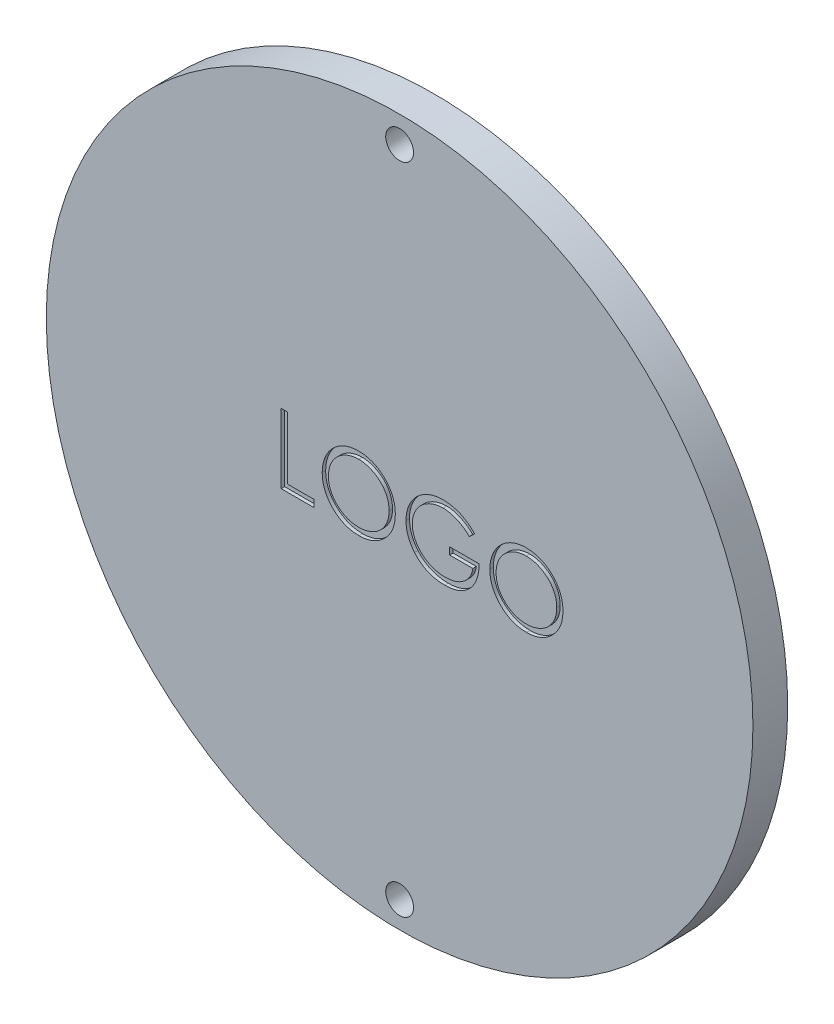
from build123d import *

# Parameters (mm, degrees)
ESQUISSE1_R             = 50.8
BOSS_EXTRU_1_DEPTH      = 5
ESQUISSE2_R             = 2
ENL_V_MAT_EXTRU_1_DEPTH = 6
ENL_V_MAT_EXTRU_2_DEPTH = 0.5


with BuildPart() as part:
    # Esquisse1 → Boss.-Extru.1 (new body)
    with BuildSketch(Plane.XY):
        Circle(ESQUISSE1_R)
    extrude(amount=BOSS_EXTRU_1_DEPTH)

    # Esquisse2 → Enlèv. mat.-Extru.1 (cut, through all)
    with BuildSketch(Plane.XY.offset(5)):
        with Locations((0, 47)):
            Circle(ESQUISSE2_R)
        with Locations((0, -47)):
            Circle(ESQUISSE2_R)
    extrude(amount=-ENL_V_MAT_EXTRU_1_DEPTH, mode=Mode.SUBTRACT)

    # Esquisse4 → Enlèv. mat.-Extru.2 (cut)
    with BuildSketch(Plane.XY.offset(5)):
        Polygon((-17.027461498, 5.640911659), (-16.1300256, 5.640911659), (-16.1300256, -3.333447315), (-12.283871754, -3.333447315), (-12.283871754, -4.359088341), (-17.027461498, -4.359088341), align=None)
        with BuildLine():
            add(Edge.make_bspline(
                [(-5.937717908, 5.897321916), (-5.752551891, 5.892631975), (-5.388870557, 5.883420544), (-4.854370849, 5.812908819), (-4.344099148, 5.690921991), (-3.853898752, 5.528456326), (-3.389633104, 5.311729511), (-2.947807697, 5.049771944), (-2.529473772, 4.739839205), (-2.140269825, 4.384327128), (-1.78410711, 3.99751726), (-1.470318863, 3.584723231), (-1.207340881, 3.148440939), (-0.991381489, 2.689981423), (-0.82195689, 2.210381514), (-0.705045337, 1.707084364), (-0.630364908, 1.183350963), (-0.621634115, 0.82613135), (-0.617205087, 0.64491807)],
                knots=[0, 0, 0, 0, 0.000555408, 0.001090868, 0.001613685, 0.002127432, 0.002637404, 0.003147577, 0.003666016, 0.004196393, 0.004726641, 0.005241469, 0.005749233, 0.006251945, 0.006759421, 0.00727203, 0.007799817, 0.008343217, 0.008343217, 0.008343217, 0.008343217], degree=3))
            add(Edge.make_bspline(
                [(-0.617205087, 0.64491807), (-0.621633466, 0.465039652), (-0.630362313, 0.11047845), (-0.705130249, -0.40993139), (-0.822390249, -0.910190523), (-0.989808152, -1.389463817), (-1.204738091, -1.848256856), (-1.469467151, -2.285362439), (-1.781299182, -2.700923862), (-2.136175899, -3.09038862), (-2.523036019, -3.447524251), (-2.937979639, -3.758721038), (-3.371674838, -4.026504252), (-3.829702576, -4.240171892), (-4.305988396, -4.410948807), (-4.804795033, -4.527384893), (-5.323785187, -4.602490731), (-5.677702341, -4.611115062), (-5.857589703, -4.615498597)],
                knots=[0, 0, 0, 0, 0.000539398, 0.001063216, 0.001573876, 0.002078799, 0.002583325, 0.003091089, 0.003609118, 0.004139494, 0.004669742, 0.005186169, 0.005693261, 0.006195974, 0.006699672, 0.007208383, 0.007730217, 0.008269615, 0.008269615, 0.008269615, 0.008269615], degree=3))
            add(Edge.make_bspline(
                [(-5.857589703, -4.615498597), (-6.038802043, -4.611071777), (-6.396019802, -4.602345338), (-6.920411332, -4.527541324), (-7.424062029, -4.41056617), (-7.905531604, -4.243396352), (-8.365088545, -4.027347122), (-8.803631639, -3.763906039), (-9.219400631, -3.451314207), (-9.608948478, -3.096552565), (-9.965374759, -2.710348131), (-10.276115832, -2.296535973), (-10.539616156, -1.863234669), (-10.754939963, -1.409241743), (-10.925409847, -0.936751906), (-11.041709327, -0.442613399), (-11.116954905, 0.070356617), (-11.125625894, 0.419622041), (-11.1300256, 0.596841147)],
                knots=[0, 0, 0, 0, 0.000543401, 0.001071187, 0.001585746, 0.002092561, 0.002597086, 0.003106566, 0.003624595, 0.004154972, 0.00468522, 0.005198842, 0.005704892, 0.006203984, 0.006703907, 0.007208722, 0.007724605, 0.008255998, 0.008255998, 0.008255998, 0.008255998], degree=3))
            add(Edge.make_bspline(
                [(-11.1300256, 0.596841147), (-11.12849807, 0.71579163), (-11.125462281, 0.952191983), (-11.088914588, 1.303239412), (-11.035881156, 1.648641291), (-10.959875691, 1.987415428), (-10.860470929, 2.318732527), (-10.743179422, 2.644877564), (-10.599922721, 2.962545346), (-10.437978012, 3.273240751), (-10.257229989, 3.572120482), (-10.057584991, 3.854633577), (-9.846055366, 4.12315071), (-9.614159956, 4.370713578), (-9.369541541, 4.604524025), (-9.108231889, 4.820988931), (-8.831825477, 5.022060219), (-8.539132963, 5.203261194), (-8.237366464, 5.367144436), (-7.926289956, 5.507778296), (-7.610128323, 5.628481329), (-7.287400757, 5.726312258), (-6.958964266, 5.803546646), (-6.624102024, 5.856139085), (-6.283080806, 5.892779994), (-6.053334181, 5.895801428), (-5.937717908, 5.897321916)],
                knots=[0, 0, 0, 0, 0.000356711, 0.000708922, 0.001057693, 0.001404687, 0.001749483, 0.002094854, 0.002443677, 0.002794014, 0.003145467, 0.003490588, 0.00383128, 0.004170059, 0.004507288, 0.004845848, 0.00518724, 0.005531867, 0.005877836, 0.006216704, 0.006555263, 0.006892386, 0.007227664, 0.007566543, 0.007908786, 0.008255486, 0.008255486, 0.008255486, 0.008255486], degree=3))
        make_face()
        with BuildLine():
            add(Edge.make_bspline(
                [(-5.893647395, 4.87168089), (-5.988546348, 4.870524061), (-6.177437014, 4.868221462), (-6.458249974, 4.837890846), (-6.735369785, 4.794662592), (-7.008853677, 4.733001104), (-7.277557361, 4.648989524), (-7.543985479, 4.552301215), (-7.80570849, 4.434526671), (-8.061862369, 4.301461801), (-8.310191155, 4.15417917), (-8.54451316, 3.991402693), (-8.765435, 3.816949681), (-8.972415761, 3.630413003), (-9.164847682, 3.430842712), (-9.346518257, 3.221264323), (-9.510145634, 2.995687491), (-9.660104425, 2.760229186), (-9.794298254, 2.515196097), (-9.913627839, 2.263167919), (-10.011239293, 2.002088814), (-10.090846082, 1.734791221), (-10.156845541, 1.461698479), (-10.198656753, 1.180738911), (-10.229320637, 0.893324305), (-10.231491624, 0.699090436), (-10.232589703, 0.600847557)],
                knots=[0, 0, 0, 0, 0.000284568, 0.000566415, 0.000846349, 0.001125772, 0.001406486, 0.001690418, 0.001975578, 0.002266767, 0.002556034, 0.002841095, 0.003122037, 0.003400029, 0.003676275, 0.003953304, 0.004231368, 0.004511451, 0.004790271, 0.005068976, 0.005347277, 0.005625492, 0.005905368, 0.006189258, 0.006477086, 0.006771666, 0.006771666, 0.006771666, 0.006771666], degree=3))
            add(Edge.make_bspline(
                [(-10.232589703, 0.600847557), (-10.22894724, 0.456384069), (-10.221781389, 0.172179697), (-10.159045474, -0.244300714), (-10.062411262, -0.644552961), (-9.919961643, -1.026386988), (-9.74181703, -1.393084939), (-9.521740201, -1.741393809), (-9.260999956, -2.071407736), (-8.964818452, -2.38082279), (-8.64103929, -2.663239374), (-8.29723149, -2.911134827), (-7.937078326, -3.120878398), (-7.559640604, -3.291750033), (-7.166933349, -3.427149284), (-6.756426061, -3.519945373), (-6.330853319, -3.581018103), (-6.040765733, -3.58688312), (-5.893647395, -3.589857571)],
                knots=[0, 0, 0, 0, 0.000433156, 0.000852151, 0.001260751, 0.001666369, 0.00207221, 0.002481815, 0.002899794, 0.003331935, 0.003764984, 0.004186943, 0.004601645, 0.005013127, 0.005428061, 0.005845469, 0.006274103, 0.006715177, 0.006715177, 0.006715177, 0.006715177], degree=3))
            add(Edge.make_bspline(
                [(-5.893647395, -3.589857571), (-5.794763105, -3.588498987), (-5.598645858, -3.585804508), (-5.306944365, -3.558665431), (-5.020498046, -3.515145804), (-4.739708675, -3.452486788), (-4.464894928, -3.374066198), (-4.194909777, -3.280901261), (-3.932628947, -3.164669251), (-3.674743696, -3.036246532), (-3.427897291, -2.889846082), (-3.192252913, -2.732594226), (-2.973750114, -2.558398166), (-2.766924196, -2.374632988), (-2.573702227, -2.177593422), (-2.395390843, -1.967535646), (-2.232590466, -1.743133768), (-2.082688618, -1.508032609), (-1.948965011, -1.262329029), (-1.832453299, -1.009387092), (-1.733607254, -0.749829637), (-1.653811526, -0.48328229), (-1.591281635, -0.210251294), (-1.54819615, 0.06962893), (-1.518057754, 0.35579848), (-1.515786104, 0.549352354), (-1.514640985, 0.646921275)],
                knots=[0, 0, 0, 0, 0.000296583, 0.000588212, 0.000878041, 0.001165283, 0.001450625, 0.001735087, 0.002021272, 0.002310637, 0.002598883, 0.002881682, 0.003159811, 0.003436463, 0.003711275, 0.003987005, 0.004262269, 0.004542353, 0.00482293, 0.005100791, 0.005377219, 0.005655434, 0.005934858, 0.006216769, 0.006504597, 0.006797175, 0.006797175, 0.006797175, 0.006797175], degree=3))
            add(Edge.make_bspline(
                [(-1.514640985, 0.646921275), (-1.515787022, 0.743822716), (-1.518060398, 0.936044573), (-1.548181754, 1.22021834), (-1.591327155, 1.498084658), (-1.65350632, 1.768552667), (-1.733649617, 2.03169131), (-1.832470561, 2.287253446), (-1.948999988, 2.536191147), (-2.082737772, 2.777889138), (-2.233068696, 3.009816961), (-2.397337963, 3.231538139), (-2.578381814, 3.438888829), (-2.7710276, 3.636987955), (-2.980087272, 3.821610497), (-3.204613827, 3.992817698), (-3.441881477, 4.154741339), (-3.69310215, 4.300814373), (-3.952370589, 4.435712181), (-4.218410469, 4.551286475), (-4.488207897, 4.649492531), (-4.761076789, 4.733255288), (-5.03931387, 4.794421089), (-5.321039095, 4.837929802), (-5.605862691, 4.868210905), (-5.797414748, 4.870520558), (-5.893647395, 4.87168089)],
                knots=[0, 0, 0, 0, 0.000290575, 0.00057641, 0.000856343, 0.001133814, 0.001408194, 0.00168088, 0.001955107, 0.002232173, 0.002508884, 0.002783725, 0.003059237, 0.003334048, 0.003612198, 0.003895069, 0.00418065, 0.004473365, 0.004766334, 0.005056992, 0.005342805, 0.005627352, 0.005912638, 0.006196528, 0.006482362, 0.006770935, 0.006770935, 0.006770935, 0.006770935], degree=3))
        make_face(mode=Mode.SUBTRACT)
        with BuildLine():
            Line((10.793051323, 3.93418089), (10.023820554, 3.205014224))
            add(Edge.make_bspline(
                [(10.023820554, 3.205014224), (9.88462373, 3.335959546), (9.609549312, 3.594727726), (9.161091476, 3.930473427), (8.693195379, 4.218090856), (8.20830253, 4.452108674), (7.718420948, 4.638830847), (7.230053016, 4.77176839), (6.748208155, 4.856547069), (6.427730388, 4.866685267), (6.269814143, 4.87168089)],
                knots=[0, 0, 0, 0, 0.000572959, 0.001132255, 0.001677141, 0.002218277, 0.002745105, 0.003247586, 0.003734987, 0.00420846, 0.00420846, 0.00420846, 0.00420846], degree=3))
            add(Edge.make_bspline(
                [(6.269814143, 4.87168089), (6.172915001, 4.870499159), (5.979368028, 4.868138762), (5.691876759, 4.838012432), (5.407400653, 4.794684249), (5.126476725, 4.73199317), (4.848558764, 4.652538714), (4.574613358, 4.553151677), (4.304129487, 4.43727955), (4.03965497, 4.303386768), (3.783253531, 4.156301493), (3.541091144, 3.993305662), (3.31162429, 3.819623406), (3.099165932, 3.630906321), (2.90249397, 3.428863849), (2.716927193, 3.217254403), (2.548992062, 2.990296636), (2.397303019, 2.752166276), (2.261984109, 2.507045735), (2.142530813, 2.257294336), (2.042253419, 2.003740466), (1.962912118, 1.746065958), (1.897453107, 1.486264273), (1.851402801, 1.2225365), (1.825440737, 0.954600256), (1.820949937, 0.775179518), (1.818692349, 0.684982172)],
                knots=[0, 0, 0, 0, 0.000290575, 0.000580397, 0.000866266, 0.001153508, 0.001443253, 0.001732833, 0.002027168, 0.00232549, 0.002621667, 0.002913352, 0.003200621, 0.003484427, 0.003764904, 0.004046067, 0.004328121, 0.004610971, 0.004892512, 0.005167594, 0.005441007, 0.005709646, 0.005975891, 0.006244298, 0.006511994, 0.006782613, 0.006782613, 0.006782613, 0.006782613], degree=3))
            add(Edge.make_bspline(
                [(1.818692349, 0.684982172), (1.820851544, 0.592779837), (1.825164038, 0.408626941), (1.852764951, 0.133786734), (1.903988495, -0.136971559), (1.972467663, -0.404537653), (2.058127136, -0.66936979), (2.164906182, -0.930319818), (2.291379327, -1.187378079), (2.437769475, -1.438228413), (2.598301485, -1.682579908), (2.778138859, -1.91274997), (2.969169098, -2.13180362), (3.178351669, -2.33487723), (3.398978932, -2.527402648), (3.637642578, -2.704075568), (3.889649608, -2.868299063), (4.155384499, -3.018003404), (4.431963878, -3.151742078), (4.715554601, -3.270667495), (5.007062645, -3.368608459), (5.304956044, -3.448431613), (5.608879678, -3.513861034), (5.920376257, -3.555953835), (6.237155424, -3.586499066), (6.450694372, -3.588732409), (6.558275682, -3.589857571)],
                knots=[0, 0, 0, 0, 0.000276624, 0.000552492, 0.000827523, 0.001102517, 0.001380616, 0.001661844, 0.001947629, 0.002239334, 0.002532686, 0.002823985, 0.003114947, 0.003403923, 0.003697903, 0.003992776, 0.004293924, 0.004599791, 0.004907092, 0.005215124, 0.005521726, 0.005828837, 0.006139999, 0.006453608, 0.006771354, 0.00709397, 0.00709397, 0.00709397, 0.00709397], degree=3))
            add(Edge.make_bspline(
                [(6.558275682, -3.589857571), (6.687928103, -3.587147353), (6.942521695, -3.5818254), (7.316768674, -3.540396002), (7.676206019, -3.475690877), (8.019823742, -3.380931172), (8.348020944, -3.260063529), (8.662000777, -3.114362425), (8.95929123, -2.938239399), (9.240786012, -2.739456922), (9.500092256, -2.517985972), (9.733961182, -2.279001814), (9.93866258, -2.023664481), (10.117247435, -1.753477866), (10.264986447, -1.466205566), (10.386251576, -1.163255387), (10.479203838, -0.844491067), (10.517360909, -0.624229262), (10.536641066, -0.512934494)],
                knots=[0, 0, 0, 0, 0.000388875, 0.000763619, 0.001128235, 0.001483486, 0.001831428, 0.00217645, 0.002520355, 0.002866631, 0.003209062, 0.003541962, 0.003868263, 0.004189401, 0.004511942, 0.00483557, 0.005167141, 0.005505795, 0.005505795, 0.005505795, 0.005505795], degree=3))
            Line((10.536641066, -0.512934494), (7.203307733, -0.512934494))
            Line((7.203307733, -0.512934494), (7.203307733, 0.512706531))
            Line((7.203307733, 0.512706531), (11.434076964, 0.512706531))
            add(Edge.make_bspline(
                [(11.434076964, 0.512706531), (11.429203111, 0.321542277), (11.419664102, -0.052600699), (11.352752914, -0.598230044), (11.244705736, -1.113577739), (11.097104845, -1.599186516), (10.906032616, -2.054368209), (10.673539677, -2.47958497), (10.395905046, -2.872089772), (10.08301807, -3.235086925), (9.731875333, -3.558884674), (9.351964991, -3.843473068), (8.942659367, -4.083194827), (8.504345631, -4.278225291), (8.038458678, -4.430436705), (7.54392045, -4.538355495), (7.021401591, -4.603012533), (6.6632968, -4.611273617), (6.480150682, -4.615498597)],
                knots=[0, 0, 0, 0, 0.000573421, 0.001122288, 0.001646393, 0.002151412, 0.002642507, 0.003124847, 0.003602241, 0.004082217, 0.004559925, 0.005032283, 0.005503654, 0.005979802, 0.006468846, 0.006971411, 0.007496175, 0.008045495, 0.008045495, 0.008045495, 0.008045495], degree=3))
            add(Edge.make_bspline(
                [(6.480150682, -4.615498597), (6.367264581, -4.613872536), (6.144616807, -4.610665421), (5.815785584, -4.587872999), (5.496020954, -4.552785639), (5.1853695, -4.499799571), (4.882688522, -4.43490056), (4.589489708, -4.351795649), (4.304656159, -4.255599365), (4.027747629, -4.146183155), (3.761277495, -4.019406993), (3.504058875, -3.878522309), (3.254669945, -3.724255564), (3.014809473, -3.553938862), (2.783227698, -3.368846118), (2.561417859, -3.16860635), (2.348138207, -2.953831722), (2.214536883, -2.801320266), (2.14721799, -2.724472956)],
                knots=[0, 0, 0, 0, 0.000338636, 0.0006679, 0.000988444, 0.001303279, 0.001612902, 0.001916684, 0.002216951, 0.00251454, 0.002809344, 0.003101593, 0.003393985, 0.003688565, 0.003983581, 0.004282864, 0.004584578, 0.004891009, 0.004891009, 0.004891009, 0.004891009], degree=3))
            add(Edge.make_bspline(
                [(2.14721799, -2.724472956), (2.049543898, -2.602556805), (1.855817005, -2.360748184), (1.606450843, -1.973319771), (1.393875407, -1.572171599), (1.221395915, -1.156186947), (1.086715668, -0.72575491), (0.990126375, -0.281425507), (0.93353412, 0.177373438), (0.925381156, 0.487845622), (0.921256451, 0.64491807)],
                knots=[0, 0, 0, 0, 0.000468399, 0.000929023, 0.001379748, 0.001828775, 0.00227798, 0.00273101, 0.003191172, 0.003662351, 0.003662351, 0.003662351, 0.003662351], degree=3))
            add(Edge.make_bspline(
                [(0.921256451, 0.64491807), (0.922777132, 0.762535934), (0.925799165, 0.996276813), (0.962443497, 1.343297691), (1.015018977, 1.684156812), (1.092296276, 2.018575544), (1.189714175, 2.346777235), (1.311295564, 2.668914274), (1.452852409, 2.985176765), (1.617382399, 3.293387816), (1.800480854, 3.589457567), (1.999195769, 3.872194148), (2.216348913, 4.136448619), (2.448394054, 4.385567614), (2.698099741, 4.616421463), (2.963126666, 4.831147493), (3.243679074, 5.030033739), (3.540639588, 5.209947552), (3.849575829, 5.371557896), (4.169747262, 5.513241358), (4.50105615, 5.630336545), (4.841020372, 5.729690202), (5.192213231, 5.803162032), (5.552086194, 5.856444161), (5.922515085, 5.892903018), (6.17290374, 5.895835177), (6.29986222, 5.897321916)],
                knots=[0, 0, 0, 0, 0.000352706, 0.00070093, 0.001045743, 0.001386877, 0.001729753, 0.002072061, 0.002419055, 0.002768555, 0.003119345, 0.003462829, 0.00380448, 0.004144624, 0.004483402, 0.004823788, 0.005167272, 0.00551426, 0.005864598, 0.006212609, 0.006563633, 0.006918042, 0.007274393, 0.007639003, 0.008009163, 0.008389904, 0.008389904, 0.008389904, 0.008389904], degree=3))
            add(Edge.make_bspline(
                [(6.29986222, 5.897321916), (6.403400059, 5.895666225), (6.608703427, 5.892383185), (6.91420552, 5.869627048), (7.214985561, 5.833558816), (7.511489532, 5.784339426), (7.802707722, 5.71730031), (8.089469737, 5.63707664), (8.372191269, 5.543671432), (8.649986267, 5.432274728), (8.924722598, 5.3058358), (9.197927857, 5.163511736), (9.46866856, 5.002868866), (9.737414221, 4.823430193), (10.005859529, 4.62827757), (10.269758507, 4.411829503), (10.535481205, 4.182621629), (10.706343532, 4.017815389), (10.793051323, 3.93418089)],
                knots=[0, 0, 0, 0, 0.0003106, 0.000615884, 0.00091852, 0.001219194, 0.001517087, 0.001814541, 0.002112271, 0.00240986, 0.002711926, 0.003019253, 0.003333603, 0.003655845, 0.003988401, 0.004328787, 0.004679485, 0.005040824, 0.005040824, 0.005040824, 0.005040824], degree=3))
        make_face()
        with BuildLine():
            add(Edge.make_bspline(
                [(18.164846195, 5.897321916), (18.350012212, 5.892631975), (18.713693546, 5.883420544), (19.248193254, 5.812908819), (19.758464954, 5.690921991), (20.248665351, 5.528456326), (20.712930998, 5.311729511), (21.154756405, 5.049771944), (21.573090331, 4.739839205), (21.962294278, 4.384327128), (22.318456993, 3.99751726), (22.632245239, 3.584723231), (22.895223221, 3.148440939), (23.111182613, 2.689981423), (23.280607213, 2.210381514), (23.397518766, 1.707084364), (23.472199195, 1.183350963), (23.480929988, 0.82613135), (23.485359015, 0.64491807)],
                knots=[0, 0, 0, 0, 0.000555408, 0.001090868, 0.001613685, 0.002127432, 0.002637404, 0.003147577, 0.003666016, 0.004196393, 0.004726641, 0.005241469, 0.005749233, 0.006251945, 0.006759421, 0.00727203, 0.007799817, 0.008343217, 0.008343217, 0.008343217, 0.008343217], degree=3))
            add(Edge.make_bspline(
                [(23.485359015, 0.64491807), (23.480930637, 0.465039652), (23.472201789, 0.11047845), (23.397433853, -0.40993139), (23.280173854, -0.910190523), (23.11275595, -1.389463817), (22.897826012, -1.848256856), (22.633096951, -2.285362439), (22.321264921, -2.700923862), (21.966388203, -3.09038862), (21.579528083, -3.447524251), (21.164584464, -3.758721038), (20.730889264, -4.026504252), (20.272861526, -4.240171892), (19.796575707, -4.410948807), (19.29776907, -4.527384893), (18.778778915, -4.602490731), (18.424861761, -4.611115062), (18.2449744, -4.615498597)],
                knots=[0, 0, 0, 0, 0.000539398, 0.001063216, 0.001573876, 0.002078799, 0.002583325, 0.003091089, 0.003609118, 0.004139494, 0.004669742, 0.005186169, 0.005693261, 0.006195974, 0.006699672, 0.007208383, 0.007730217, 0.008269615, 0.008269615, 0.008269615, 0.008269615], degree=3))
            add(Edge.make_bspline(
                [(18.2449744, -4.615498597), (18.06376206, -4.611071777), (17.7065443, -4.602345338), (17.18215277, -4.527541324), (16.678502074, -4.41056617), (16.197032499, -4.243396352), (15.737475557, -4.027347122), (15.298932464, -3.763906039), (14.883163472, -3.451314207), (14.493615624, -3.096552565), (14.137189344, -2.710348131), (13.826448271, -2.296535973), (13.562947947, -1.863234669), (13.34762414, -1.409241743), (13.177154256, -0.936751906), (13.060854775, -0.442613399), (12.985609198, 0.070356617), (12.976938208, 0.419622041), (12.972538502, 0.596841147)],
                knots=[0, 0, 0, 0, 0.000543401, 0.001071187, 0.001585746, 0.002092561, 0.002597086, 0.003106566, 0.003624595, 0.004154972, 0.00468522, 0.005198842, 0.005704892, 0.006203984, 0.006703907, 0.007208722, 0.007724605, 0.008255998, 0.008255998, 0.008255998, 0.008255998], degree=3))
            add(Edge.make_bspline(
                [(12.972538502, 0.596841147), (12.974066032, 0.71579163), (12.977101822, 0.952191983), (13.013649515, 1.303239412), (13.066682947, 1.648641291), (13.142688411, 1.987415428), (13.242093174, 2.318732527), (13.359384681, 2.644877564), (13.502641382, 2.962545346), (13.664586091, 3.273240751), (13.845334113, 3.572120482), (14.044979112, 3.854633577), (14.256508736, 4.12315071), (14.488404146, 4.370713578), (14.733022561, 4.604524025), (14.994332213, 4.820988931), (15.270738626, 5.022060219), (15.563431139, 5.203261194), (15.865197639, 5.367144436), (16.176274147, 5.507778296), (16.49243578, 5.628481329), (16.815163345, 5.726312258), (17.143599837, 5.803546646), (17.478462078, 5.856139085), (17.819483296, 5.892779994), (18.049229922, 5.895801428), (18.164846195, 5.897321916)],
                knots=[0, 0, 0, 0, 0.000356711, 0.000708922, 0.001057693, 0.001404687, 0.001749483, 0.002094854, 0.002443677, 0.002794014, 0.003145467, 0.003490588, 0.00383128, 0.004170059, 0.004507288, 0.004845848, 0.00518724, 0.005531867, 0.005877836, 0.006216704, 0.006555263, 0.006892386, 0.007227664, 0.007566543, 0.007908786, 0.008255486, 0.008255486, 0.008255486, 0.008255486], degree=3))
        make_face()
        with BuildLine():
            add(Edge.make_bspline(
                [(18.208916708, 4.87168089), (18.114017755, 4.870524061), (17.925127089, 4.868221462), (17.644314128, 4.837890846), (17.367194317, 4.794662592), (17.093710425, 4.733001104), (16.825006742, 4.648989524), (16.558578624, 4.552301215), (16.296855613, 4.434526671), (16.040701733, 4.301461801), (15.792372947, 4.15417917), (15.558050943, 3.991402693), (15.337129103, 3.816949681), (15.130148341, 3.630413003), (14.937716421, 3.430842712), (14.756045845, 3.221264323), (14.592418469, 2.995687491), (14.442459678, 2.760229186), (14.308265849, 2.515196097), (14.188936264, 2.263167919), (14.09132481, 2.002088814), (14.011718021, 1.734791221), (13.945718561, 1.461698479), (13.903907349, 1.180738911), (13.873243465, 0.893324305), (13.871072478, 0.699090436), (13.8699744, 0.600847557)],
                knots=[0, 0, 0, 0, 0.000284568, 0.000566415, 0.000846349, 0.001125772, 0.001406486, 0.001690418, 0.001975578, 0.002266767, 0.002556034, 0.002841095, 0.003122037, 0.003400029, 0.003676275, 0.003953304, 0.004231368, 0.004511451, 0.004790271, 0.005068976, 0.005347277, 0.005625492, 0.005905368, 0.006189258, 0.006477086, 0.006771666, 0.006771666, 0.006771666, 0.006771666], degree=3))
            add(Edge.make_bspline(
                [(13.8699744, 0.600847557), (13.873616863, 0.456384069), (13.880782714, 0.172179697), (13.943518628, -0.244300714), (14.040152841, -0.644552961), (14.182602459, -1.026386988), (14.360747073, -1.393084939), (14.580823902, -1.741393809), (14.841564146, -2.071407736), (15.137745651, -2.38082279), (15.461524813, -2.663239374), (15.805332613, -2.911134827), (16.165485777, -3.120878398), (16.542923499, -3.291750033), (16.935630753, -3.427149284), (17.346138042, -3.519945373), (17.771710784, -3.581018103), (18.06179837, -3.58688312), (18.208916708, -3.589857571)],
                knots=[0, 0, 0, 0, 0.000433156, 0.000852151, 0.001260751, 0.001666369, 0.00207221, 0.002481815, 0.002899794, 0.003331935, 0.003764984, 0.004186943, 0.004601645, 0.005013127, 0.005428061, 0.005845469, 0.006274103, 0.006715177, 0.006715177, 0.006715177, 0.006715177], degree=3))
            add(Edge.make_bspline(
                [(18.208916708, -3.589857571), (18.307800998, -3.588498987), (18.503918245, -3.585804508), (18.795619737, -3.558665431), (19.082066056, -3.515145804), (19.362855427, -3.452486788), (19.637669174, -3.374066198), (19.907654326, -3.280901261), (20.169935155, -3.164669251), (20.427820406, -3.036246532), (20.674666811, -2.889846082), (20.910311189, -2.732594226), (21.128813989, -2.558398166), (21.335639907, -2.374632988), (21.528861876, -2.177593422), (21.707173259, -1.967535646), (21.869973637, -1.743133768), (22.019875484, -1.508032609), (22.153599092, -1.262329029), (22.270110804, -1.009387092), (22.368956849, -0.749829637), (22.448752577, -0.48328229), (22.511282467, -0.210251294), (22.554367953, 0.06962893), (22.584506349, 0.35579848), (22.586777998, 0.549352354), (22.587923118, 0.646921275)],
                knots=[0, 0, 0, 0, 0.000296583, 0.000588212, 0.000878041, 0.001165283, 0.001450625, 0.001735087, 0.002021272, 0.002310637, 0.002598883, 0.002881682, 0.003159811, 0.003436463, 0.003711275, 0.003987005, 0.004262269, 0.004542353, 0.00482293, 0.005100791, 0.005377219, 0.005655434, 0.005934858, 0.006216769, 0.006504597, 0.006797175, 0.006797175, 0.006797175, 0.006797175], degree=3))
            add(Edge.make_bspline(
                [(22.587923118, 0.646921275), (22.586777081, 0.743822716), (22.584503705, 0.936044573), (22.554382349, 1.22021834), (22.511236948, 1.498084658), (22.449057782, 1.768552667), (22.368914486, 2.03169131), (22.270093542, 2.287253446), (22.153564115, 2.536191147), (22.019826331, 2.777889138), (21.869495406, 3.009816961), (21.70522614, 3.231538139), (21.524182288, 3.438888829), (21.331536503, 3.636987955), (21.12247683, 3.821610497), (20.897950276, 3.992817698), (20.660682625, 4.154741339), (20.409461952, 4.300814373), (20.150193513, 4.435712181), (19.884153633, 4.551286475), (19.614356206, 4.649492531), (19.341487313, 4.733255288), (19.063250232, 4.794421089), (18.781525007, 4.837929802), (18.496701411, 4.868210905), (18.305149355, 4.870520558), (18.208916708, 4.87168089)],
                knots=[0, 0, 0, 0, 0.000290575, 0.00057641, 0.000856343, 0.001133814, 0.001408194, 0.00168088, 0.001955107, 0.002232173, 0.002508884, 0.002783725, 0.003059237, 0.003334048, 0.003612198, 0.003895069, 0.00418065, 0.004473365, 0.004766334, 0.005056992, 0.005342805, 0.005627352, 0.005912638, 0.006196528, 0.006482362, 0.006770935, 0.006770935, 0.006770935, 0.006770935], degree=3))
        make_face(mode=Mode.SUBTRACT)
    extrude(amount=-ENL_V_MAT_EXTRU_2_DEPTH, mode=Mode.SUBTRACT)


solid = part.part
